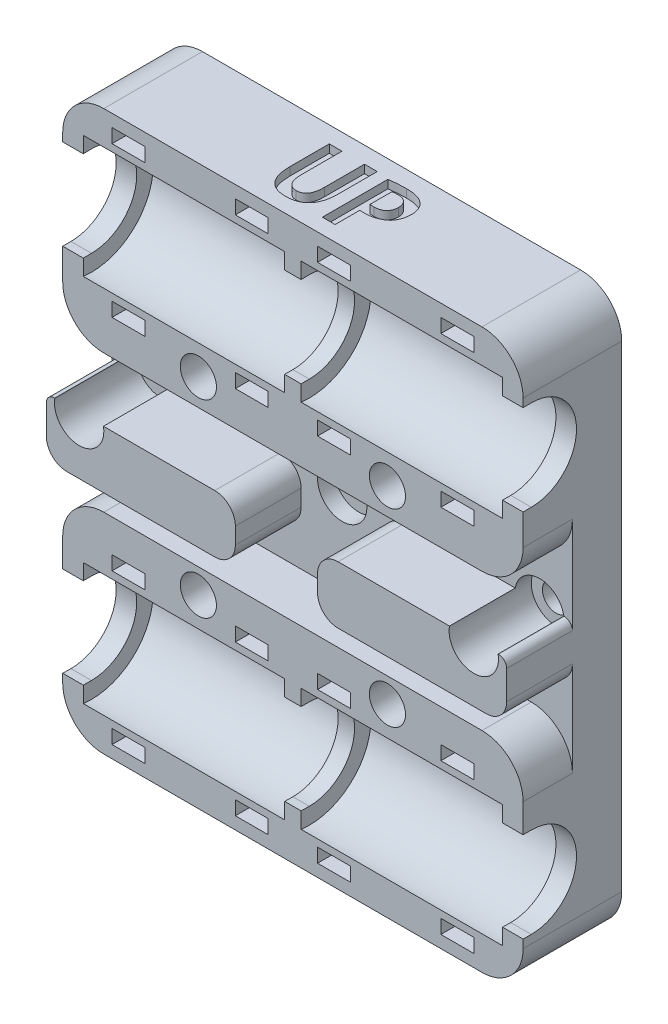
from build123d import *

# Parameters (mm, degrees)
EXTRUDE1_DEPTH      = 28
EXTRUDE1_DEPTH_BACK = 28
SKETCH3_W           = 6
SKETCH3_H           = 68
EXTRUDE2_DEPTH      = 28
EXTRUDE2_DEPTH_BACK = 28
SKETCH4_W           = 6
SKETCH4_H           = 25.481815629
SKETCH4_H_2         = 25.75
EXTRUDE3_DEPTH      = 4
EXTRUDE3_DEPTH_BACK = 55
SKETCH6_R           = 7.5
EXTRUDE4_DEPTH      = 24.5
EXTRUDE5_START      = -24.5
SKETCH7_R           = 7.5
EXTRUDE5_DEPTH      = 24.5
SKETCH8_W           = 23
SKETCH8_H           = 7
EXTRUDE6_DEPTH      = 8
SKETCH9_R           = 2.2
EXTRUDE7_DEPTH      = 14
SKETCH10_R          = 1.65
EXTRUDE8_DEPTH      = 14
SKETCH11_R          = 3
EXTRUDE9_DEPTH      = 10
SKETCH12_W          = 4
SKETCH12_H          = 20
EXTRUDE12_DEPTH     = 1.2
SKETCH14_W          = 4
SKETCH14_H          = 1.7
EXTRUDE13_DEPTH     = 12
FILLET1_R           = 5
FILLET2_R           = 5
FILLET3_R           = 2.5
FILLET4_R           = 1
FILLET5_R           = 3
FILLET7_R           = 2
EXTRUDE14_DEPTH     = 1


with BuildPart() as part:
    # Sketch3 → Extrude1 (new, two sides: drawn at the far end of the back side and taken through both)
    with BuildSketch(Plane(origin=(0, 0, 0), x_dir=(0, 0, -1), z_dir=(1, 0, 0)).offset(-EXTRUDE1_DEPTH_BACK)):
        with Locations((11, 0)):
            Rectangle(SKETCH3_W, SKETCH3_H)
    extrude(amount=EXTRUDE1_DEPTH + EXTRUDE1_DEPTH_BACK)

    # Sketch4 → Extrude2 (add, two sides: drawn at the far end of the back side and taken through both)
    with BuildSketch(Plane(origin=(0, 0, 0), x_dir=(0, 0, -1), z_dir=(1, 0, 0)).offset(-EXTRUDE2_DEPTH_BACK)):
        with Locations((5, -21.259092186)):
            Rectangle(SKETCH4_W, SKETCH4_H)
        with Locations((5, 21.125)):
            Rectangle(SKETCH4_W, SKETCH4_H_2)
    extrude(amount=EXTRUDE2_DEPTH + EXTRUDE2_DEPTH_BACK)

    # Sketch5 → Extrude3 (cut, two sides: drawn at the far end of the back side and taken through both)
    with BuildSketch(Plane(origin=(25.5, 0, 0), x_dir=(0, 0, -1), z_dir=(1, 0, 0)).offset(-EXTRUDE3_DEPTH_BACK)):
        with BuildLine():
            ThreePointArc((3, 17), (8.5, 22.5), (3, 28))
            Line((3, 28), (-0.943696246, 27.935982376))
            Line((-0.943696246, 27.935982376), (-0.766173544, 17))
            Line((-0.766173544, 17), (3, 17))
        make_face()
        with BuildLine():
            Line((-0.766173544, -17), (-0.943696246, -27.935982376))
            Line((-0.943696246, -27.935982376), (3, -28))
            ThreePointArc((3, -28), (8.5, -22.5), (3, -17))
            Line((3, -17), (-0.766173544, -17))
        make_face()
    extrude(amount=EXTRUDE3_DEPTH + EXTRUDE3_DEPTH_BACK, mode=Mode.SUBTRACT)

    # Sketch6 → Extrude4 (cut)
    with BuildSketch(Plane(origin=(1, 0, 0), x_dir=(0, 0, -1), z_dir=(1, 0, 0))):
        with Locations((3, 22.5)):
            Circle(SKETCH6_R)
        with Locations((3, -22.5)):
            Circle(SKETCH6_R)
    extrude(amount=EXTRUDE4_DEPTH, mode=Mode.SUBTRACT)

    # Sketch7 → Extrude5 (cut)
    with BuildSketch(Plane(origin=(-1, 0, 0), x_dir=(0, 0, -1), z_dir=(1, 0, 0)).offset(EXTRUDE5_START)):
        with Locations((3, 22.5)):
            Circle(SKETCH7_R)
        with Locations((3, -22.5)):
            Circle(SKETCH7_R)
    extrude(amount=EXTRUDE5_DEPTH, mode=Mode.SUBTRACT)

    # Sketch8 → Extrude6 (add)
    with BuildSketch(Plane.XY.offset(-8)):
        with Locations((16.5, -0.989696402)):
            Rectangle(SKETCH8_W, SKETCH8_H)
        with Locations((-16.5, -0.989696402)):
            Rectangle(SKETCH8_W, SKETCH8_H)
    extrude(amount=EXTRUDE6_DEPTH)

    # Sketch9 → Extrude7 (cut)
    with BuildSketch(Plane.XY):
        with Locations((-11.499999862, 11.49999829)):
            Circle(SKETCH9_R)
        with Locations((-11.499999862, -11.49999829)):
            Circle(SKETCH9_R)
        with Locations((11.499999862, -11.49999829)):
            Circle(SKETCH9_R)
        with Locations((11.499999862, 11.49999829)):
            Circle(SKETCH9_R)
    extrude(amount=-EXTRUDE7_DEPTH, mode=Mode.SUBTRACT)

    # Sketch10 → Extrude8 (cut)
    with BuildSketch(Plane.XY):
        with Locations((0, 2)):
            Circle(SKETCH10_R)
        with Locations((24, 2)):
            Circle(SKETCH10_R)
        with Locations((-24, 2)):
            Circle(SKETCH10_R)
    extrude(amount=-EXTRUDE8_DEPTH, mode=Mode.SUBTRACT)

    # Sketch11 → Extrude9 (cut)
    with BuildSketch(Plane.XY):
        with Locations((0, 2)):
            Circle(SKETCH11_R)
        with Locations((24, 2)):
            Circle(SKETCH11_R)
        with Locations((-24, 2)):
            Circle(SKETCH11_R)
    extrude(amount=-EXTRUDE9_DEPTH, mode=Mode.SUBTRACT)

    # Sketch12 → Extrude12 (cut)
    with BuildSketch(Plane(origin=(0, 0, -14), x_dir=(-1, 0, 0), z_dir=(0, 0, -1))):
        with Locations((-5, 22.5)):
            Rectangle(SKETCH12_W, SKETCH12_H)
        with Locations((-20, 22.5)):
            Rectangle(SKETCH12_W, SKETCH12_H)
        with Locations((20, 22.5)):
            Rectangle(SKETCH12_W, SKETCH12_H)
        with Locations((5, 22.5)):
            Rectangle(SKETCH12_W, SKETCH12_H)
        with Locations((5, -22.5)):
            Rectangle(SKETCH12_W, SKETCH12_H)
        with Locations((20, -22.5)):
            Rectangle(SKETCH12_W, SKETCH12_H)
        with Locations((-20, -22.5)):
            Rectangle(SKETCH12_W, SKETCH12_H)
        with Locations((-5, -22.5)):
            Rectangle(SKETCH12_W, SKETCH12_H)
    extrude(amount=-EXTRUDE12_DEPTH, mode=Mode.SUBTRACT)

    # Sketch14 → Extrude13 (cut)
    with BuildSketch(Plane(origin=(0, 0, -14), x_dir=(-1, 0, 0), z_dir=(0, 0, -1))):
        with Locations((-20, 31.65)):
            Rectangle(SKETCH14_W, SKETCH14_H)
        with Locations((-20, 13.35)):
            Rectangle(SKETCH14_W, SKETCH14_H)
        with Locations((-5, 31.65)):
            Rectangle(SKETCH14_W, SKETCH14_H)
        with Locations((-5, 13.35)):
            Rectangle(SKETCH14_W, SKETCH14_H)
        with Locations((5, 13.35)):
            Rectangle(SKETCH14_W, SKETCH14_H)
        with Locations((5, 31.65)):
            Rectangle(SKETCH14_W, SKETCH14_H)
        with Locations((20, 13.35)):
            Rectangle(SKETCH14_W, SKETCH14_H)
        with Locations((20, 31.65)):
            Rectangle(SKETCH14_W, SKETCH14_H)
        with Locations((20, -31.65)):
            Rectangle(SKETCH14_W, SKETCH14_H)
        with Locations((20, -13.35)):
            Rectangle(SKETCH14_W, SKETCH14_H)
        with Locations((5, -31.65)):
            Rectangle(SKETCH14_W, SKETCH14_H)
        with Locations((5, -13.35)):
            Rectangle(SKETCH14_W, SKETCH14_H)
        with Locations((-5, -13.35)):
            Rectangle(SKETCH14_W, SKETCH14_H)
        with Locations((-5, -31.65)):
            Rectangle(SKETCH14_W, SKETCH14_H)
        with Locations((-20, -13.35)):
            Rectangle(SKETCH14_W, SKETCH14_H)
        with Locations((-20, -31.65)):
            Rectangle(SKETCH14_W, SKETCH14_H)
    extrude(amount=-EXTRUDE13_DEPTH, mode=Mode.SUBTRACT)

    # Fillet1
    fillet1_edges = [part.edges().sort_by_distance(p)[0] for p in [
        (28, 34, -8),
        (28, -34, -8),
        (-28, -34, -8),
        (-28, 34, -8),
    ]]
    fillet(fillet1_edges, radius=FILLET1_R)

    # Fillet2
    fillet2_edges = [part.edges().sort_by_distance(p)[0] for p in [
        (28, 8.25, -5),
        (-28, 8.25, -5),
        (28, -8.518184371, -5),
        (-28, -8.518184371, -5),
    ]]
    fillet(fillet2_edges, radius=FILLET2_R)

    # Fillet3
    fillet3_edges = [part.edges().sort_by_distance(p)[0] for p in [
        (28, -4.489696402, -4),
        (-28, -4.489696402, -4),
        (5, -4.489696402, -4),
        (5, 2.510303598, -4),
        (-5, -4.489696402, -4),
        (-5, 2.510303598, -4),
    ]]
    fillet(fillet3_edges, radius=FILLET3_R)

    # Fillet4
    fillet4_edges = [part.edges().sort_by_distance(p)[0] for p in [
        (28, 2.510303598, -4),
        (-28, 2.510303598, -4),
    ]]
    fillet(fillet4_edges, radius=FILLET4_R)

    # Fillet5
    fillet5_edges = [part.edges().sort_by_distance(p)[0] for p in [
        (-20, -30.8, -12.8),
        (-5, -30.8, -12.8),
        (5, -30.8, -12.8),
        (20, -30.8, -12.8),
        (20, -14.2, -12.8),
        (5, -14.2, -12.8),
        (-5, -14.2, -12.8),
        (-20, -14.2, -12.8),
        (-20, 30.8, -12.8),
        (-20, 14.2, -12.8),
        (-5, 14.2, -12.8),
        (-5, 30.8, -12.8),
        (5, 30.8, -12.8),
        (5, 14.2, -12.8),
        (20, 14.2, -12.8),
        (20, 30.8, -12.8),
    ]]
    fillet(fillet5_edges, radius=FILLET5_R)

    # Fillet7
    fillet7_edges = [part.edges().sort_by_distance(p)[0] for p in [
        (20, 12.5, -14),
        (5, 12.5, -14),
        (-5, 12.5, -14),
        (-20, 12.5, -14),
        (-20, -12.5, -14),
        (-5, -12.5, -14),
        (5, -12.5, -14),
        (20, -12.5, -14),
    ]]
    fillet(fillet7_edges, radius=FILLET7_R)

    # Sketch15 → Extrude14 (cut)
    # profile 1 of 2: a face of its own
    with BuildSketch(Plane(origin=(0, 34, 0), x_dir=(1, 0, 0), z_dir=(0, 1, 0))):
        with BuildLine():
            Line((-1.281385828, 11.99238348), (-1.281385828, 7.101161653))
            add(Edge.make_bspline(
                [(-1.281385828, 7.101161653), (-1.283048838, 7.014407486), (-1.286252655, 6.847274107), (-1.304979898, 6.605566754), (-1.332500207, 6.382213048), (-1.373798485, 6.177356479), (-1.425144856, 5.991021867), (-1.486836939, 5.822263645), (-1.561638172, 5.672381633), (-1.647065175, 5.539754122), (-1.744068014, 5.42571432), (-1.847412239, 5.324386921), (-1.963289256, 5.243064681), (-2.085148634, 5.172820001), (-2.217729323, 5.121350603), (-2.358191426, 5.085068234), (-2.507748683, 5.063020932), (-2.610332309, 5.061372071), (-2.663165245, 5.06052287)],
                knots=[0, 0, 0, 0, 1.489993247, 2.870497347, 4.161855382, 5.352763325, 6.456165467, 7.478921399, 8.433502261, 9.32760426, 10.180962719, 11.000518916, 11.805685981, 12.605366645, 13.411052033, 14.239405808, 15.093253336, 16, 16, 16, 16], degree=3))
            add(Edge.make_bspline(
                [(-2.663165245, 5.06052287), (-2.7134932, 5.061233154), (-2.812172432, 5.062625825), (-2.955336482, 5.087023421), (-3.091369947, 5.1224462), (-3.218529797, 5.177298185), (-3.339714711, 5.245057085), (-3.4506437, 5.331453015), (-3.554148065, 5.432042732), (-3.650115012, 5.547956823), (-3.737306436, 5.680680003), (-3.811669267, 5.831773618), (-3.875799856, 5.999766931), (-3.926423541, 6.186069277), (-3.967410479, 6.389430614), (-3.997695803, 6.610479719), (-4.015465755, 6.849352798), (-4.018851147, 7.014467423), (-4.020599046, 7.099717145)],
                knots=[0, 0, 0, 0, 0.872891072, 1.711498532, 2.515084453, 3.308659782, 4.109633667, 4.920191743, 5.742584798, 6.612268993, 7.528582619, 8.49385913, 9.531184336, 10.646949603, 11.842566077, 13.132094952, 14.519282547, 16, 16, 16, 16], degree=3))
            Line((-4.020599046, 7.099717145), (-4.020599046, 11.99238348))
            Line((-4.020599046, 11.99238348), (-5.566735893, 11.99238348))
            Line((-5.566735893, 11.99238348), (-5.566735893, 7.237905489))
            add(Edge.make_bspline(
                [(-5.566735893, 7.237905489), (-5.564417576, 7.094884007), (-5.559936465, 6.818435628), (-5.525116095, 6.418297973), (-5.46636419, 6.047464119), (-5.384719284, 5.705900398), (-5.281702781, 5.39319627), (-5.15586805, 5.109180738), (-5.004365998, 4.855324481), (-4.831909427, 4.629356384), (-4.636391145, 4.432665175), (-4.420404887, 4.26310037), (-4.184490447, 4.118204845), (-3.926394339, 4.003702033), (-3.650201244, 3.910619458), (-3.352579355, 3.850742555), (-3.036100047, 3.810561276), (-2.81801668, 3.807926575), (-2.705775275, 3.806570569)],
                knots=[0, 0, 0, 0, 1.342034137, 2.594038022, 3.765602397, 4.862464202, 5.886101928, 6.851335094, 7.771410383, 8.65403833, 9.512391257, 10.366629074, 11.225496653, 12.103258761, 13.010985816, 13.95488923, 14.947438721, 16, 16, 16, 16], degree=3))
            add(Edge.make_bspline(
                [(-2.705775275, 3.806570569), (-2.592041208, 3.808060034), (-2.370476985, 3.810961645), (-2.047875665, 3.849570707), (-1.74479058, 3.915084726), (-1.460780106, 4.005599435), (-1.196677855, 4.124009941), (-0.951291736, 4.267168837), (-0.726102196, 4.439074416), (-0.521090744, 4.638110269), (-0.337379365, 4.864385248), (-0.17812084, 5.12019538), (-0.042789256, 5.40460948), (0.067593918, 5.718002582), (0.154303645, 6.059774015), (0.215362861, 6.429884812), (0.253568734, 6.829070661), (0.259935909, 7.104700718), (0.263230719, 7.247330462)],
                knots=[0, 0, 0, 0, 1.051426476, 2.048273633, 2.998859571, 3.91577204, 4.799894893, 5.67050817, 6.537536653, 7.413443073, 8.307357971, 9.226380492, 10.193767482, 11.21470055, 12.294558713, 13.450725732, 14.680832061, 16, 16, 16, 16], degree=3))
            Line((0.263230719, 7.247330462), (0.264751019, 11.99238348))
            Line((0.264751019, 11.99238348), (-1.281385828, 11.99238348))
        make_face()
    # profile 2 of 2: a face of its own
    with BuildSketch(Plane(origin=(0, 34, 0), x_dir=(1, 0, 0), z_dir=(0, 1, 0))):
        with BuildLine():
            Line((3.283977462, 3.847597881), (3.283977462, 6.87753479))
            add(Edge.make_bspline(
                [(3.283977462, 6.87753479), (3.324447486, 6.8695995), (3.409445337, 6.852933273), (3.544164084, 6.844164409), (3.690107305, 6.832644134), (3.791207667, 6.833143649), (3.843994994, 6.83340446)],
                knots=[0, 0, 0, 0, 0.878556077, 1.845202224, 2.874919808, 4, 4, 4, 4], degree=3))
            add(Edge.make_bspline(
                [(3.843994994, 6.83340446), (3.925181171, 6.832159059), (4.088287543, 6.829656998), (4.333624676, 6.848610578), (4.579850135, 6.886829603), (4.826335525, 6.94518021), (5.073346623, 7.021610031), (5.321118706, 7.116238862), (5.568520925, 7.2314122), (5.815835388, 7.360707658), (6.052714578, 7.515839267), (6.258899537, 7.712982228), (6.439602382, 7.93981811), (6.586905693, 8.202758013), (6.707835222, 8.497485762), (6.797300977, 8.826243117), (6.860445573, 9.187517703), (6.877294431, 9.439963278), (6.886046753, 9.571098863)],
                knots=[0, 0, 0, 0, 0.841321464, 1.69024945, 2.54697463, 3.421933785, 4.313421963, 5.225513963, 6.16898692, 7.140527675, 8.117658811, 9.092268315, 10.084297122, 11.113479625, 12.205185911, 13.378908979, 14.638445907, 16, 16, 16, 16], degree=3))
            add(Edge.make_bspline(
                [(6.886046753, 9.571098863), (6.883427257, 9.663572391), (6.878278695, 9.845327122), (6.837485718, 10.110403078), (6.773970119, 10.362667969), (6.684064888, 10.599825047), (6.571555715, 10.820699204), (6.438807943, 11.022603105), (6.286125316, 11.205432698), (6.167690849, 11.308922742), (6.108413712, 11.360720108)],
                knots=[0, 0, 0, 0, 1.10039744, 2.162807532, 3.18512533, 4.192295778, 5.175353367, 6.130031606, 7.064069995, 8, 8, 8, 8], degree=3))
            add(Edge.make_bspline(
                [(6.108413712, 11.360720108), (6.041003569, 11.411028683), (5.904187407, 11.513135369), (5.674157289, 11.63914575), (5.422115206, 11.745528923), (5.146812604, 11.831728726), (4.848652875, 11.899065379), (4.52731769, 11.942534395), (4.183373582, 11.971212023), (3.946525786, 11.97305066), (3.824211766, 11.974000177)],
                knots=[0, 0, 0, 0, 0.836606025, 1.697982253, 2.603178176, 3.556730869, 4.566307281, 5.642647, 6.782605007, 8, 8, 8, 8], degree=3))
            add(Edge.make_bspline(
                [(3.824211766, 11.974000177), (3.716153017, 11.973019348), (3.506578595, 11.97111708), (3.200711148, 11.959424147), (2.913076184, 11.94593404), (2.642496616, 11.930297584), (2.390959039, 11.906796009), (2.156469375, 11.881225923), (1.940075846, 11.851865412), (1.802181315, 11.826383299), (1.736320314, 11.814212566)],
                knots=[0, 0, 0, 0, 1.236942669, 2.398987101, 3.50349081, 4.533253662, 5.501087568, 6.394974819, 7.233410034, 8, 8, 8, 8], degree=3))
            Line((1.736320314, 11.814212566), (1.737840615, 3.847597881))
            Line((1.737840615, 3.847597881), (3.283977462, 3.847597881))
        make_face()
        with BuildLine():
            add(Edge.make_bspline(
                [(3.283977462, 10.755592892), (3.322415565, 10.764200839), (3.41025529, 10.783871936), (3.56070119, 10.799192104), (3.743787252, 10.814046558), (3.876921268, 10.816249556), (3.948998282, 10.81744223)],
                knots=[0, 0, 0, 0, 0.70585537, 1.613038518, 2.7077303, 4, 4, 4, 4], degree=3))
            add(Edge.make_bspline(
                [(3.948998282, 10.81744223), (4.00130376, 10.816896948), (4.103666908, 10.815829817), (4.252553683, 10.797842375), (4.393238766, 10.772923414), (4.524755393, 10.736353716), (4.647598867, 10.688924473), (4.761594129, 10.631001163), (4.868383166, 10.563675443), (4.965081289, 10.484664009), (5.052962386, 10.395843944), (5.129044081, 10.296654019), (5.193884475, 10.18751331), (5.245010113, 10.067927068), (5.286374341, 9.939049294), (5.316677497, 9.800508982), (5.334816281, 9.651712632), (5.338177605, 9.549337097), (5.339911392, 9.496531312)],
                knots=[0, 0, 0, 0, 1.150647283, 2.251845908, 3.296564491, 4.293585939, 5.251638342, 6.190496202, 7.10431693, 8.025138136, 8.933209785, 9.848938853, 10.770098533, 11.720244083, 12.705502524, 13.745915437, 14.837332513, 16, 16, 16, 16], degree=3))
            add(Edge.make_bspline(
                [(5.339911392, 9.496531312), (5.338089497, 9.44272589), (5.334521379, 9.337349795), (5.317269181, 9.18373742), (5.284413178, 9.039280056), (5.241282485, 8.903717312), (5.183533177, 8.77802485), (5.117307181, 8.659435352), (5.035674698, 8.551254662), (4.942896022, 8.452165221), (4.838656564, 8.363516468), (4.724189705, 8.285361388), (4.598834056, 8.220102148), (4.463093375, 8.166450578), (4.317856804, 8.124392325), (4.16209356, 8.093624937), (3.996577099, 8.075853766), (3.882588199, 8.07239065), (3.824211766, 8.070617106)],
                knots=[0, 0, 0, 0, 1.095951735, 2.146384348, 3.141117811, 4.107846426, 5.036936284, 5.952845255, 6.867880406, 7.788493674, 8.711536769, 9.648229827, 10.604475232, 11.582556545, 12.615324965, 13.678675286, 14.811194273, 16, 16, 16, 16], degree=3))
            add(Edge.make_bspline(
                [(3.824211766, 8.070617106), (3.771436938, 8.070563484), (3.67089656, 8.070461329), (3.527843025, 8.079023314), (3.399873246, 8.08886384), (3.320910614, 8.104426318), (3.283977462, 8.111705349)],
                knots=[0, 0, 0, 0, 1.166410307, 2.222107342, 3.16842715, 4, 4, 4, 4], degree=3))
            Line((3.283977462, 8.111705349), (3.283977462, 10.755592892))
        make_face(mode=Mode.SUBTRACT)
    extrude(amount=-EXTRUDE14_DEPTH, mode=Mode.SUBTRACT)


solid = part.part
